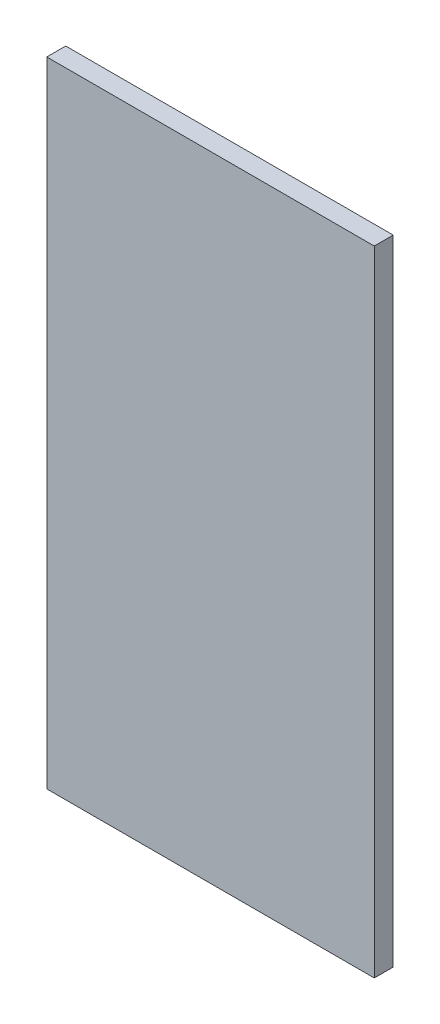
from build123d import *

# Parameters (mm, degrees)
SKETCH1_W           = 311
SKETCH1_H           = 602
BOSS_EXTRUDE1_DEPTH = 18


with BuildPart() as part:
    # Sketch1 → Boss-Extrude1 (new body)
    with BuildSketch(Plane.XY):
        Rectangle(SKETCH1_W, SKETCH1_H)
    extrude(amount=BOSS_EXTRUDE1_DEPTH)


solid = part.part
